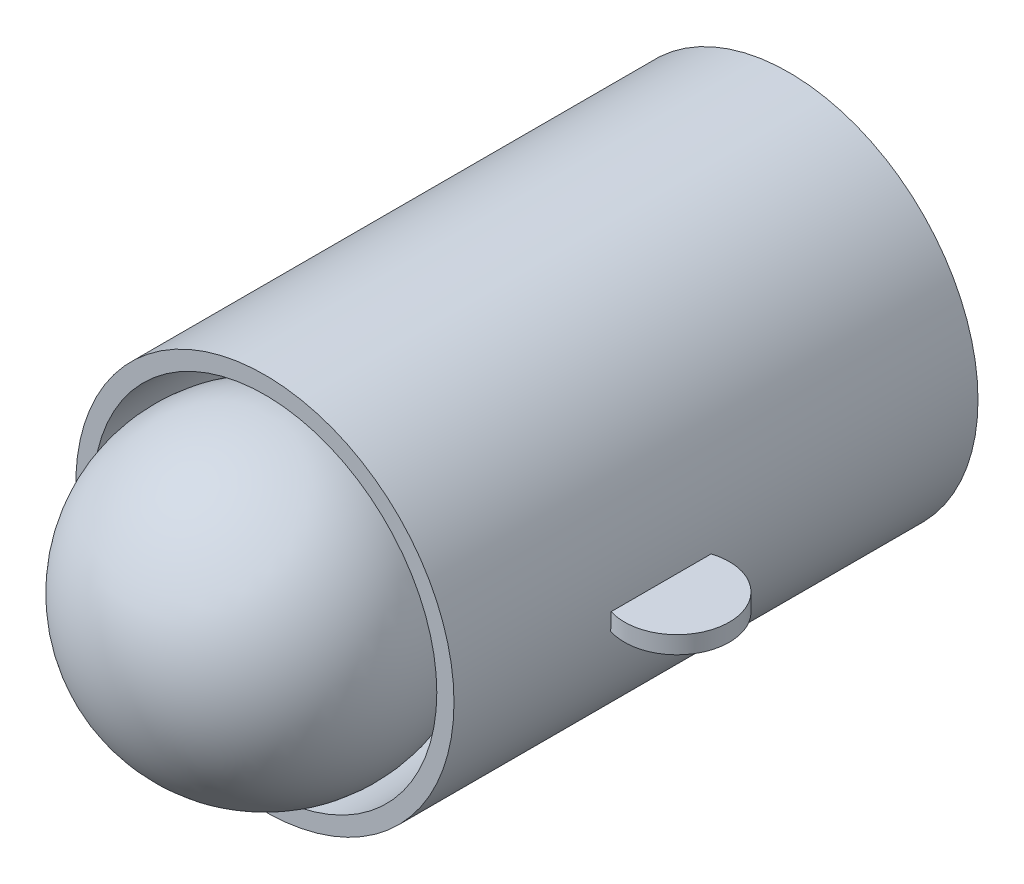
from build123d import *

# Parameters (mm, degrees)
SKETCH1_R           = 27.5
BOSS_EXTRUDE1_DEPTH = 76.2
SKETCH2_R           = 25
CUT_EXTRUDE1_DEPTH  = 76.2
SKETCH6_R           = 7.62
BOSS_EXTRUDE3_DEPTH = 2.54


with BuildPart() as part:
    # Sketch1 → Boss-Extrude1 (new body)
    with BuildSketch(Plane.XY):
        Circle(SKETCH1_R)
    extrude(amount=BOSS_EXTRUDE1_DEPTH)

    # Sketch2 → Cut-Extrude1 (cut)
    with BuildSketch(Plane.XY.offset(76.2)):
        Circle(SKETCH2_R)
    extrude(amount=-CUT_EXTRUDE1_DEPTH, mode=Mode.SUBTRACT)

    # Sketch6 → Boss-Extrude3 (add)
    with BuildSketch(Plane(origin=(0, 0, 0), x_dir=(-1, 0, 0), z_dir=(0, -1, 0))):
        with Locations((-29.793262581, -46.07327125)):
            Circle(SKETCH6_R)
    extrude(amount=BOSS_EXTRUDE3_DEPTH)


with BuildPart() as body_2:
    # Sketch3 → Revolve-Thin1 (revolve)
    with BuildSketch(Plane.XY.offset(76.2)):
        with BuildLine():
            ThreePointArc((0, -20), (20, 0), (0, 20))
            Line((0, 20), (0, 22.54))
            ThreePointArc((0, 22.54), (22.54, 0), (0, -22.54))
            Line((0, -22.54), (0, -20))
        make_face()
    revolve(axis=Axis((0, 27.5, 76.2), (0, -1, 0)))


solid = Compound([part.part, body_2.part])
